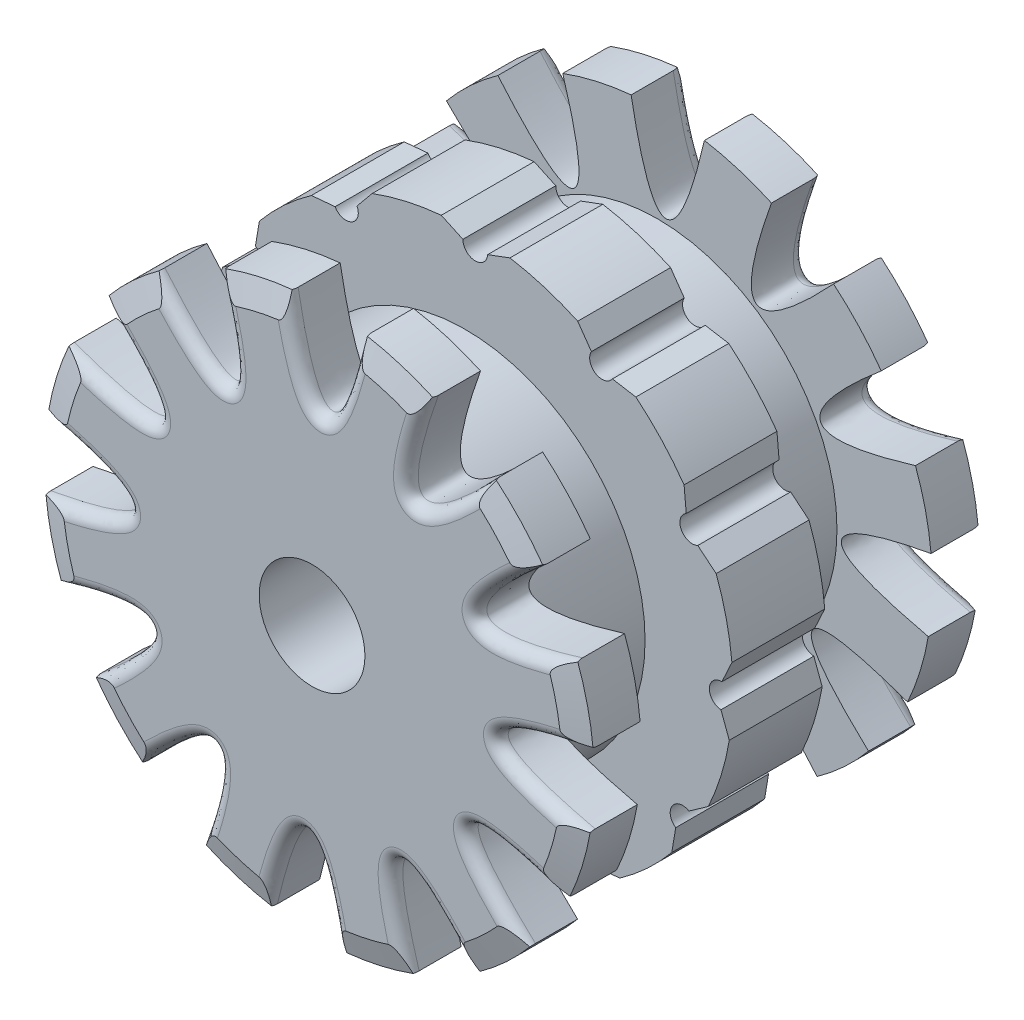
from build123d import *

# Parameters (mm, degrees)
BOSS_EXTRUDE1_DEPTH    = 9.525
CUT_EXTRUDE1_REACH     = 11.525
SKETCH2_R              = 9.525
BOSS_EXTRUDE2_DEPTH    = 9.525
CIRPATTERN1_COUNT      = 12
SKETCH4_R              = 18.415
SKETCH4_R_2            = 12.7
BOSS_EXTRUDE3_DEPTH    = 10.16
SKETCH5_R              = 28.194
SKETCH5_R_2            = 12.7
BOSS_EXTRUDE4_DEPTH    = 5.588
CUT_EXTRUDE2_DEPTH     = 5.588
SKETCH7_R              = 12.7
SKETCH7_R_2            = 5.425
BOSS_EXTRUDE5_DEPTH    = 15.748
CHAMFER1_SIZE          = 0.762
CHAMFER1_SIZE2         = 2.54
CHAMFER1_PART_2_SIZE   = 0.762
CHAMFER1_PART_2_SIZE2  = 2.54
CHAMFER1_PART_3_SIZE   = 0.762
CHAMFER1_PART_3_SIZE2  = 2.54
CHAMFER1_PART_4_SIZE   = 0.762
CHAMFER1_PART_4_SIZE2  = 2.54
CHAMFER1_PART_5_SIZE   = 0.762
CHAMFER1_PART_5_SIZE2  = 2.54
CHAMFER1_PART_6_SIZE   = 0.762
CHAMFER1_PART_6_SIZE2  = 2.54
CHAMFER1_PART_7_SIZE   = 0.762
CHAMFER1_PART_7_SIZE2  = 2.54
CHAMFER1_PART_8_SIZE   = 0.762
CHAMFER1_PART_8_SIZE2  = 2.54
CHAMFER1_PART_9_SIZE   = 0.762
CHAMFER1_PART_9_SIZE2  = 2.54
CHAMFER1_PART_10_SIZE  = 0.762
CHAMFER1_PART_10_SIZE2 = 2.54
CHAMFER1_PART_11_SIZE  = 0.762
CHAMFER1_PART_11_SIZE2 = 2.54
CHAMFER1_PART_12_SIZE  = 0.762
CHAMFER1_PART_12_SIZE2 = 2.54
CHAMFER2_SIZE          = 2.54
CHAMFER2_SIZE2         = 0.762
FILLET1_R              = 1.27
FILLET2_R              = 1.27


with BuildPart() as part:
    # Sketch1 → Boss-Extrude1 (new body)
    with BuildSketch(Plane.XY):
        with BuildLine():
            ThreePointArc((-22.908668154, 12.910363879), (-21.183606568, 13.325171874), (-21.556636689, 15.059747232))
            ThreePointArc((-21.556636689, 15.059747232), (-17.876342879, 19.285251808), (-13.384306649, 22.635037168))
            ThreePointArc((-13.384306649, 22.635037168), (-11.682955495, 22.131740636), (-11.138721377, 23.820442022))
            ThreePointArc((-11.138721377, 23.820442022), (-5.838741156, 25.639689424), (-0.273630986, 26.294670527))
            ThreePointArc((-0.273630986, 26.294670527), (0.948134068, 25.008127369), (2.263805333, 26.198468609))
            ThreePointArc((2.263805333, 26.198468609), (7.763346545, 25.123992964), (12.910363879, 22.908668154))
            ThreePointArc((12.910363879, 22.908668154), (13.325171874, 21.183606568), (15.059747232, 21.556636689))
            ThreePointArc((15.059747232, 21.556636689), (19.285251808, 17.876342879), (22.635037168, 13.384306649))
            ThreePointArc((22.635037168, 13.384306649), (22.131740636, 11.682955495), (23.820442022, 11.138721377))
            ThreePointArc((23.820442022, 11.138721377), (25.639689424, 5.838741156), (26.294670527, 0.273630986))
            ThreePointArc((26.294670527, 0.273630986), (25.008127369, -0.948134068), (26.198468609, -2.263805333))
            ThreePointArc((26.198468609, -2.263805333), (25.123992964, -7.763346545), (22.908668154, -12.910363879))
            ThreePointArc((22.908668154, -12.910363879), (21.183606568, -13.325171874), (21.556636689, -15.059747232))
            ThreePointArc((21.556636689, -15.059747232), (17.876342879, -19.285251808), (13.384306649, -22.635037168))
            ThreePointArc((13.384306649, -22.635037168), (11.682955495, -22.131740636), (11.138721377, -23.820442022))
            ThreePointArc((11.138721377, -23.820442022), (5.838741156, -25.639689424), (0.273630986, -26.294670527))
            ThreePointArc((0.273630986, -26.294670527), (-0.948134068, -25.008127369), (-2.263805333, -26.198468609))
            ThreePointArc((-2.263805333, -26.198468609), (-7.763346545, -25.123992964), (-12.910363879, -22.908668154))
            ThreePointArc((-12.910363879, -22.908668154), (-13.325171874, -21.183606568), (-15.059747232, -21.556636689))
            ThreePointArc((-15.059747232, -21.556636689), (-19.285251808, -17.876342879), (-22.635037168, -13.384306649))
            ThreePointArc((-22.635037168, -13.384306649), (-22.131740636, -11.682955495), (-23.820442022, -11.138721377))
            ThreePointArc((-23.820442022, -11.138721377), (-25.639689424, -5.838741156), (-26.294670527, -0.273630986))
            ThreePointArc((-26.294670527, -0.273630986), (-25.008127369, 0.948134068), (-26.198468609, 2.263805333))
            ThreePointArc((-26.198468609, 2.263805333), (-25.123992964, 7.763346545), (-22.908668154, 12.910363879))
        make_face()
    extrude(amount=BOSS_EXTRUDE1_DEPTH)

    # Sketch2 → Cut-Extrude1 (cut, up to next)
    with BuildSketch(Plane(origin=(0, 0, 0), x_dir=(-1, 0, 0), z_dir=(0, 0, -1)), mode=Mode.PRIVATE) as cut_extrude1_sk1:
        Circle(SKETCH2_R)
    cut_extrude1_tool1 = extrude(cut_extrude1_sk1.sketch, amount=-CUT_EXTRUDE1_REACH, mode=Mode.PRIVATE) & part.part
    add(cut_extrude1_tool1.solids().sort_by_distance((0, 0, 0))[0], mode=Mode.SUBTRACT)

    # Sketch3 → Boss-Extrude2 (add)
    with BuildSketch(Plane(origin=(0, 0, 0), x_dir=(-1, 0, 0), z_dir=(0, 0, -1))):
        with BuildLine():
            Line((-0.273630986, -26.294670527), (-2.49022744, -27.320009707))
            ThreePointArc((-2.49022744, -27.320009707), (-6.091237211, -26.748476448), (-9.584649142, -25.704448329))
            Line((-9.584649142, -25.704448329), (-11.138721377, -23.820442022))
            ThreePointArc((-11.138721377, -23.820442022), (-5.838741156, -25.639689424), (-0.273630986, -26.294670527))
        make_face()
    boss_extrude2 = extrude(amount=-BOSS_EXTRUDE2_DEPTH)

    # CirPattern1: Boss-Extrude2 ×12 about axis
    cirpattern1_axis = Axis((0, 0, 0), (0, 0, 1))
    for i in range(1, CIRPATTERN1_COUNT):
        add(boss_extrude2.rotate(cirpattern1_axis, i * 360 / CIRPATTERN1_COUNT))

    # Sketch4 → Boss-Extrude3 (add)
    with BuildSketch(Plane(origin=(0, 0, 0), x_dir=(-1, 0, 0), z_dir=(0, 0, -1))):
        Circle(SKETCH4_R)
        Circle(SKETCH4_R_2, mode=Mode.SUBTRACT)
    boss_extrude3 = extrude(amount=BOSS_EXTRUDE3_DEPTH)

    # Sketch5 → Boss-Extrude4 (add)
    with BuildSketch(Plane(origin=(0, 0, -10.16), x_dir=(-1, 0, 0), z_dir=(0, 0, -1))):
        Circle(SKETCH5_R)
        Circle(SKETCH5_R_2, mode=Mode.SUBTRACT)
    boss_extrude4 = extrude(amount=BOSS_EXTRUDE4_DEPTH)

    # Sketch6 → Cut-Extrude2 (cut)
    with BuildSketch(Plane(origin=(0, 0, -15.748), x_dir=(-1, 0, 0), z_dir=(0, 0, -1))):
        with BuildLine():
            ThreePointArc((11.692251315, -25.65527032), (15.011926842, -23.865114466), (18.062961317, -21.647888222))
            add(Edge.make_bspline(
                [(18.062961317, -21.647888222), (5.4553558, -8.151615299), (11.692251315, -25.65527032)],
                knots=[0, 0, 0, 1, 1, 1], degree=2))
        make_face()
        with BuildLine():
            ThreePointArc((-2.701848494, -28.064241495), (1.068152772, -28.173758813), (4.819039257, -27.779101797))
            add(Edge.make_bspline(
                [(4.819039257, -27.779101797), (0.64866906, -9.78718383), (-2.701848494, -28.064241495)],
                knots=[0, 0, 0, 1, 1, 1], degree=2))
        make_face()
        with BuildLine():
            ThreePointArc((-16.371990181, -22.953421826), (-13.161831971, -24.933267238), (-9.71614048, -26.466927479))
            add(Edge.make_bspline(
                [(-9.71614048, -26.466927479), (-4.331828031, -8.800284358), (-16.371990181, -22.953421826)],
                knots=[0, 0, 0, 1, 1, 1], degree=2))
        make_face()
        with BuildLine():
            ThreePointArc((-25.65527032, -11.692251315), (-23.865114466, -15.011926842), (-21.647888222, -18.062961317))
            add(Edge.make_bspline(
                [(-21.647888222, -18.062961317), (-8.151615299, -5.4553558), (-25.65527032, -11.692251315)],
                knots=[0, 0, 0, 1, 1, 1], degree=2))
        make_face()
        with BuildLine():
            ThreePointArc((-28.064241495, 2.701848494), (-28.173758813, -1.068152772), (-27.779101797, -4.819039257))
            add(Edge.make_bspline(
                [(-27.779101797, -4.819039257), (-9.78718383, -0.64866906), (-28.064241495, 2.701848494)],
                knots=[0, 0, 0, 1, 1, 1], degree=2))
        make_face()
        with BuildLine():
            ThreePointArc((-22.953421826, 16.371990181), (-24.933267238, 13.161831971), (-26.466927479, 9.71614048))
            add(Edge.make_bspline(
                [(-26.466927479, 9.71614048), (-8.800284358, 4.331828031), (-22.953421826, 16.371990181)],
                knots=[0, 0, 0, 1, 1, 1], degree=2))
        make_face()
        with BuildLine():
            ThreePointArc((-11.692251315, 25.65527032), (-15.011926842, 23.865114466), (-18.062961317, 21.647888222))
            add(Edge.make_bspline(
                [(-18.062961317, 21.647888222), (-5.4553558, 8.151615299), (-11.692251315, 25.65527032)],
                knots=[0, 0, 0, 1, 1, 1], degree=2))
        make_face()
        with BuildLine():
            ThreePointArc((2.701848494, 28.064241495), (-1.068152772, 28.173758813), (-4.819039257, 27.779101797))
            add(Edge.make_bspline(
                [(-4.819039257, 27.779101797), (-0.64866906, 9.78718383), (2.701848494, 28.064241495)],
                knots=[0, 0, 0, 1, 1, 1], degree=2))
        make_face()
        with BuildLine():
            ThreePointArc((16.371990181, 22.953421826), (13.161831971, 24.933267238), (9.71614048, 26.466927479))
            add(Edge.make_bspline(
                [(9.71614048, 26.466927479), (4.331828031, 8.800284358), (16.371990181, 22.953421826)],
                knots=[0, 0, 0, 1, 1, 1], degree=2))
        make_face()
        with BuildLine():
            ThreePointArc((25.65527032, 11.692251315), (23.865114466, 15.011926842), (21.647888222, 18.062961317))
            add(Edge.make_bspline(
                [(21.647888222, 18.062961317), (8.151615299, 5.4553558), (25.65527032, 11.692251315)],
                knots=[0, 0, 0, 1, 1, 1], degree=2))
        make_face()
        with BuildLine():
            ThreePointArc((28.064241495, -2.701848494), (28.173758813, 1.068152772), (27.779101797, 4.819039257))
            add(Edge.make_bspline(
                [(27.779101797, 4.819039257), (9.78718383, 0.64866906), (28.064241495, -2.701848494)],
                knots=[0, 0, 0, 1, 1, 1], degree=2))
        make_face()
        with BuildLine():
            ThreePointArc((22.953421826, -16.371990181), (24.933267238, -13.161831971), (26.466927479, -9.71614048))
            add(Edge.make_bspline(
                [(26.466927479, -9.71614048), (8.800284358, -4.331828031), (22.953421826, -16.371990181)],
                knots=[0, 0, 0, 1, 1, 1], degree=2))
        make_face()
    cut_extrude2 = extrude(amount=-CUT_EXTRUDE2_DEPTH, mode=Mode.SUBTRACT)

    # Mirror1: Boss-Extrude3, Boss-Extrude4, Cut-Extrude2 across plane
    add(boss_extrude3.mirror(Plane(origin=(0, 0, 4.7625), x_dir=(1, 0, 0), z_dir=(0, 0, -1))))
    add(boss_extrude4.mirror(Plane(origin=(0, 0, 4.7625), x_dir=(1, 0, 0), z_dir=(0, 0, -1))))
    add(cut_extrude2.mirror(Plane(origin=(0, 0, 4.7625), x_dir=(1, 0, 0), z_dir=(0, 0, -1))), mode=Mode.SUBTRACT)

    # Sketch7 → Boss-Extrude5 (add)
    with BuildSketch(Plane.XY.offset(9.525)):
        Circle(SKETCH7_R)
        Circle(SKETCH7_R_2, mode=Mode.SUBTRACT)
    extrude(amount=BOSS_EXTRUDE5_DEPTH)

    # Chamfer1
    chamfer1_edges = [part.edges().sort_by_distance(p)[0] for p in [
        (-26.937302981, 8.323661701, -15.748),
    ]]
    chamfer1_side = [part.faces().sort_by_distance(p)[0] for p in [
        (-26.937302981, 8.323661701, -12.954),
    ]]
    chamfer(chamfer1_edges, length=CHAMFER1_SIZE, length2=CHAMFER1_SIZE2, reference=chamfer1_side[0])

    # Chamfer1 part 2
    chamfer1_part_2_edges = [part.edges().sort_by_distance(p)[0] for p in [
        (-27.490219542, -6.260149005, -15.748),
    ]]
    chamfer1_part_2_side = [part.faces().sort_by_distance(p)[0] for p in [
        (-27.490219542, -6.260149005, -12.954),
    ]]
    chamfer(chamfer1_part_2_edges, length=CHAMFER1_PART_2_SIZE, length2=CHAMFER1_PART_2_SIZE2, reference=chamfer1_part_2_side[0])

    # Chamfer1 part 3
    chamfer1_part_3_edges = [part.edges().sort_by_distance(p)[0] for p in [
        (-20.677153976, -19.16655784, -15.748),
    ]]
    chamfer1_part_3_side = [part.faces().sort_by_distance(p)[0] for p in [
        (-20.677153976, -19.16655784, -12.954),
    ]]
    chamfer(chamfer1_part_3_edges, length=CHAMFER1_PART_3_SIZE, length2=CHAMFER1_PART_3_SIZE2, reference=chamfer1_part_3_side[0])

    # Chamfer1 part 4
    chamfer1_part_4_edges = [part.edges().sort_by_distance(p)[0] for p in [
        (-8.323661701, -26.937302981, -15.748),
    ]]
    chamfer1_part_4_side = [part.faces().sort_by_distance(p)[0] for p in [
        (-8.323661701, -26.937302981, -12.954),
    ]]
    chamfer(chamfer1_part_4_edges, length=CHAMFER1_PART_4_SIZE, length2=CHAMFER1_PART_4_SIZE2, reference=chamfer1_part_4_side[0])

    # Chamfer1 part 5
    chamfer1_part_5_edges = [part.edges().sort_by_distance(p)[0] for p in [
        (-19.16655784, 20.677153976, -15.748),
    ]]
    chamfer1_part_5_side = [part.faces().sort_by_distance(p)[0] for p in [
        (-19.16655784, 20.677153976, -12.954),
    ]]
    chamfer(chamfer1_part_5_edges, length=CHAMFER1_PART_5_SIZE, length2=CHAMFER1_PART_5_SIZE2, reference=chamfer1_part_5_side[0])

    # Chamfer1 part 6
    chamfer1_part_6_edges = [part.edges().sort_by_distance(p)[0] for p in [
        (-6.260149005, 27.490219542, -15.748),
    ]]
    chamfer1_part_6_side = [part.faces().sort_by_distance(p)[0] for p in [
        (-6.260149005, 27.490219542, -12.954),
    ]]
    chamfer(chamfer1_part_6_edges, length=CHAMFER1_PART_6_SIZE, length2=CHAMFER1_PART_6_SIZE2, reference=chamfer1_part_6_side[0])

    # Chamfer1 part 7
    chamfer1_part_7_edges = [part.edges().sort_by_distance(p)[0] for p in [
        (8.323661701, 26.937302981, -15.748),
    ]]
    chamfer1_part_7_side = [part.faces().sort_by_distance(p)[0] for p in [
        (8.323661701, 26.937302981, -12.954),
    ]]
    chamfer(chamfer1_part_7_edges, length=CHAMFER1_PART_7_SIZE, length2=CHAMFER1_PART_7_SIZE2, reference=chamfer1_part_7_side[0])

    # Chamfer1 part 8
    chamfer1_part_8_edges = [part.edges().sort_by_distance(p)[0] for p in [
        (20.677153976, 19.16655784, -15.748),
    ]]
    chamfer1_part_8_side = [part.faces().sort_by_distance(p)[0] for p in [
        (20.677153976, 19.16655784, -12.954),
    ]]
    chamfer(chamfer1_part_8_edges, length=CHAMFER1_PART_8_SIZE, length2=CHAMFER1_PART_8_SIZE2, reference=chamfer1_part_8_side[0])

    # Chamfer1 part 9
    chamfer1_part_9_edges = [part.edges().sort_by_distance(p)[0] for p in [
        (27.490219542, 6.260149005, -15.748),
    ]]
    chamfer1_part_9_side = [part.faces().sort_by_distance(p)[0] for p in [
        (27.490219542, 6.260149005, -12.954),
    ]]
    chamfer(chamfer1_part_9_edges, length=CHAMFER1_PART_9_SIZE, length2=CHAMFER1_PART_9_SIZE2, reference=chamfer1_part_9_side[0])

    # Chamfer1 part 10
    chamfer1_part_10_edges = [part.edges().sort_by_distance(p)[0] for p in [
        (26.937302981, -8.323661701, -15.748),
    ]]
    chamfer1_part_10_side = [part.faces().sort_by_distance(p)[0] for p in [
        (26.937302981, -8.323661701, -12.954),
    ]]
    chamfer(chamfer1_part_10_edges, length=CHAMFER1_PART_10_SIZE, length2=CHAMFER1_PART_10_SIZE2, reference=chamfer1_part_10_side[0])

    # Chamfer1 part 11
    chamfer1_part_11_edges = [part.edges().sort_by_distance(p)[0] for p in [
        (19.16655784, -20.677153976, -15.748),
    ]]
    chamfer1_part_11_side = [part.faces().sort_by_distance(p)[0] for p in [
        (19.16655784, -20.677153976, -12.954),
    ]]
    chamfer(chamfer1_part_11_edges, length=CHAMFER1_PART_11_SIZE, length2=CHAMFER1_PART_11_SIZE2, reference=chamfer1_part_11_side[0])

    # Chamfer1 part 12
    chamfer1_part_12_edges = [part.edges().sort_by_distance(p)[0] for p in [
        (6.260149005, -27.490219542, -15.748),
    ]]
    chamfer1_part_12_side = [part.faces().sort_by_distance(p)[0] for p in [
        (6.260149005, -27.490219542, -12.954),
    ]]
    chamfer(chamfer1_part_12_edges, length=CHAMFER1_PART_12_SIZE, length2=CHAMFER1_PART_12_SIZE2, reference=chamfer1_part_12_side[0])

    # Chamfer2
    chamfer2_edges = [part.edges().sort_by_distance(p)[0] for p in [
        (6.260149005, -27.490219542, 25.273),
        (19.16655784, -20.677153976, 25.273),
        (26.937302981, -8.323661701, 25.273),
        (27.490219542, 6.260149005, 25.273),
        (20.677153976, 19.16655784, 25.273),
        (8.323661701, 26.937302981, 25.273),
        (-6.260149005, 27.490219542, 25.273),
        (-19.16655784, 20.677153976, 25.273),
        (-26.937302981, 8.323661701, 25.273),
        (-27.490219542, -6.260149005, 25.273),
        (-20.677153976, -19.16655784, 25.273),
        (-8.323661701, -26.937302981, 25.273),
    ]]
    chamfer2_side = [part.faces().sort_by_distance(p)[0] for p in [
        (-18.060090857, 0.882478665, 25.273),
    ]]
    chamfer(chamfer2_edges, length=CHAMFER2_SIZE, length2=CHAMFER2_SIZE2, reference=chamfer2_side[0])

    # Fillet1
    fillet1_edges = [part.edges().sort_by_distance(p)[0] for p in [
        (-16.753714907, -8.69083043, -15.748),
        (-10.163727502, -15.903337386, -15.748),
        (-0.850377521, -18.854557933, -15.748),
        (8.69083043, -16.753714907, -15.748),
        (15.903337386, -10.163727502, -15.748),
        (-18.854557933, 0.850377521, -15.748),
        (-15.903337386, 10.163727502, -15.748),
        (-8.69083043, 16.753714907, -15.748),
        (0.850377521, 18.854557933, -15.748),
        (10.163727502, 15.903337386, -15.748),
        (16.753714907, 8.69083043, -15.748),
        (18.854557933, -0.850377521, -15.748),
    ]]
    fillet(fillet1_edges, radius=FILLET1_R)

    # Fillet2
    fillet2_edges = [part.edges().sort_by_distance(p)[0] for p in [
        (18.854557933, -0.850377521, 25.273),
        (16.753714907, 8.69083043, 25.273),
        (10.163727502, 15.903337386, 25.273),
        (0.850377521, 18.854557933, 25.273),
        (-8.69083043, 16.753714907, 25.273),
        (15.903337386, -10.163727502, 25.273),
        (8.69083043, -16.753714907, 25.273),
        (-0.850377521, -18.854557933, 25.273),
        (-10.163727502, -15.903337386, 25.273),
        (-16.753714907, -8.69083043, 25.273),
        (-18.854557933, 0.850377521, 25.273),
        (-15.903337386, 10.163727502, 25.273),
    ]]
    fillet(fillet2_edges, radius=FILLET2_R)


solid = part.part
